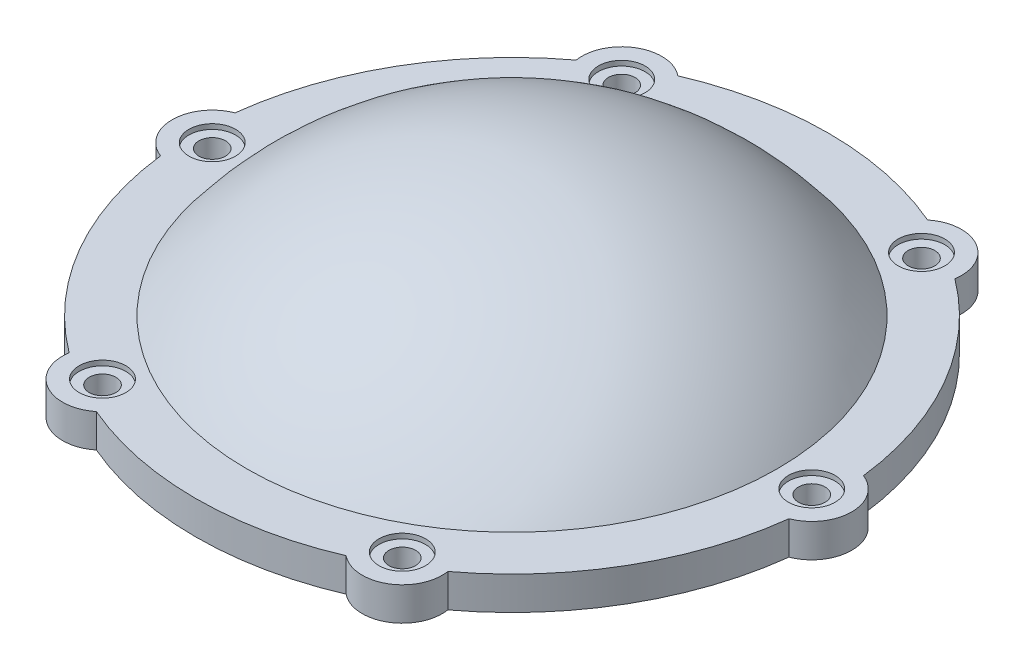
from build123d import *

# Parameters (mm, degrees)
EXTRUDE_1_DEPTH          = 5
PATTERN_CIRCULAR_1_COUNT = 6


with BuildPart() as part:
    # 草圖1 → 旋轉1 (revolve)
    with BuildSketch(Plane.XY):
        with BuildLine():
            Line((39.811273529, 6.5), (47.5, 6.5))
            Line((47.5, 6.5), (47.5, 1.5))
            Line((47.5, 1.5), (42, 1.5))
            Line((42, 1.5), (42, 0))
            Line((42, 0), (40, 0))
            Line((40, 0), (40, 0.927925359))
            ThreePointArc((40, 0.927925359), (22.903465984, 17.291823131), (0, 23.25))
            Line((0, 23.25), (0, 26.25))
            ThreePointArc((0, 26.25), (22.220486043, 21.041182168), (39.811273529, 6.5))
        make_face()
    revolve(axis=Axis((0, 0, 0), (0, 1, 0)))

    # 草圖3 → 填料-伸長1 (add)
    with BuildSketch(Plane(origin=(0, 6.5, 0), x_dir=(1, 0, 0), z_dir=(0, 1, 0))):
        with BuildLine():
            ThreePointArc((44.6, 5.986651819), (51, 0), (44.6, -5.986651819))
            ThreePointArc((44.6, -5.986651819), (45, 0), (44.6, 5.986651819))
        make_face()
        with BuildLine():
            ThreePointArc((27.484592559, -35.631407099), (25.5, -44.167295593), (17.115407441, -41.618058918))
            ThreePointArc((17.115407441, -41.618058918), (22.5, -38.97114317), (27.484592559, -35.631407099))
        make_face()
        with BuildLine():
            ThreePointArc((-17.115407441, -41.618058918), (-25.5, -44.167295593), (-27.484592559, -35.631407099))
            ThreePointArc((-27.484592559, -35.631407099), (-22.5, -38.97114317), (-17.115407441, -41.618058918))
        make_face()
        with BuildLine():
            ThreePointArc((-44.6, -5.986651819), (-51, 0), (-44.6, 5.986651819))
            ThreePointArc((-44.6, 5.986651819), (-45, 0), (-44.6, -5.986651819))
        make_face()
        with BuildLine():
            ThreePointArc((-27.484592559, 35.631407099), (-25.5, 44.167295593), (-17.115407441, 41.618058918))
            ThreePointArc((-17.115407441, 41.618058918), (-22.5, 38.97114317), (-27.484592559, 35.631407099))
        make_face()
        with BuildLine():
            ThreePointArc((17.115407441, 41.618058918), (25.5, 44.167295593), (27.484592559, 35.631407099))
            ThreePointArc((27.484592559, 35.631407099), (22.5, 38.97114317), (17.115407441, 41.618058918))
        make_face()
    extrude(amount=-EXTRUDE_1_DEPTH)

    # 草圖5 → 除料-旋轉1 (revolve, cut)
    with BuildSketch(Plane.XY):
        Polygon((48.5, 6.5), (48.5, 5.75), (47, 5.75), (47, 1.5), (45, 1.5), (45, 6.5), align=None)
    cut_revolve_1 = revolve(axis=Axis((45, 6.5, 0), (0, -1, 0)), mode=Mode.SUBTRACT)

    # 環狀複製排列1: 除料-旋轉1 ×6 about axis
    pattern_circular_1_axis = Axis((0, 0, 0), (0, 1, 0))
    for i in range(1, PATTERN_CIRCULAR_1_COUNT):
        add(cut_revolve_1.rotate(pattern_circular_1_axis, i * 360 / PATTERN_CIRCULAR_1_COUNT), mode=Mode.SUBTRACT)


solid = part.part
